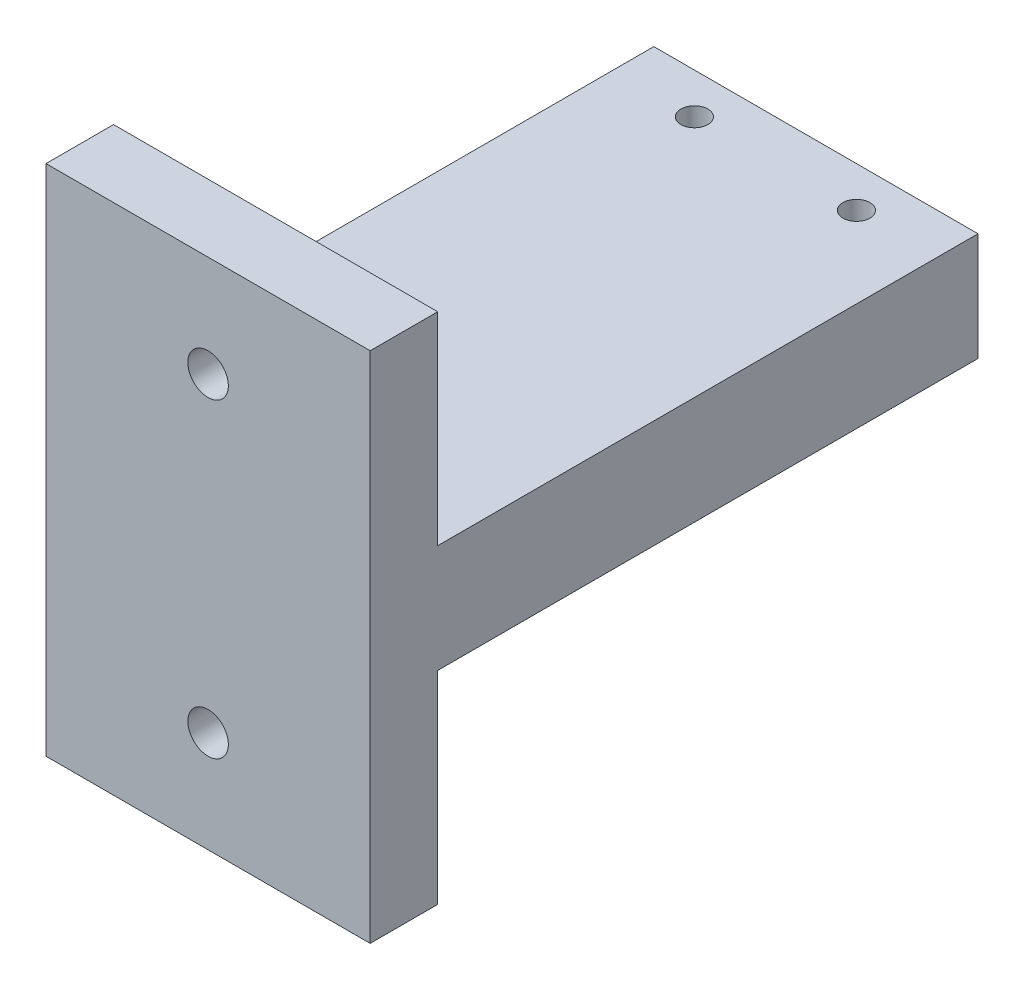
from build123d import *

# Parameters (mm, degrees)
SKETCH2_W           = 24
SKETCH2_H           = 45
BOSS_EXTRUDE1_DEPTH = 8
SKETCH5_W           = 24
SKETCH5_H           = 5
BOSS_EXTRUDE2_DEPTH = 15
SKETCH6_W           = 24
SKETCH6_H           = 5
BOSS_EXTRUDE3_DEPTH = 15
SKETCH7_R           = 1.5
CUT_EXTRUDE1_DEPTH  = 5
SKETCH8_R           = 1
CUT_EXTRUDE2_DEPTH  = 4


with BuildPart() as part:
    # Sketch2 → Boss-Extrude1 (new body)
    with BuildSketch(Plane(origin=(0, 0, 0), x_dir=(1, 0, 0), z_dir=(0, 1, 0))):
        with Locations((-7.196993829, 1.750308141)):
            Rectangle(SKETCH2_W, SKETCH2_H)
    extrude(amount=BOSS_EXTRUDE1_DEPTH)

    # Sketch5 → Boss-Extrude2 (add)
    with BuildSketch(Plane(origin=(0, 8, 0), x_dir=(1, 0, 0), z_dir=(0, 1, 0))):
        with Locations((-7.196993829, -18.249691859)):
            Rectangle(SKETCH5_W, SKETCH5_H)
    extrude(amount=BOSS_EXTRUDE2_DEPTH)

    # Sketch6 → Boss-Extrude3 (add)
    with BuildSketch(Plane.XZ):
        with Locations((-7.196993829, 18.249691859)):
            Rectangle(SKETCH6_W, SKETCH6_H)
    extrude(amount=BOSS_EXTRUDE3_DEPTH)

    # Sketch7 → Cut-Extrude1 (cut)
    with BuildSketch(Plane(origin=(0, 0, 15.749691859), x_dir=(-1, 0, 0), z_dir=(0, 0, -1))):
        with Locations((7.196993829, 15.5)):
            Circle(SKETCH7_R)
        with Locations((7.196993829, -7.5)):
            Circle(SKETCH7_R)
    extrude(amount=-CUT_EXTRUDE1_DEPTH, mode=Mode.SUBTRACT)

    # Sketch8 → Cut-Extrude2 (cut)
    with BuildSketch(Plane(origin=(0, 8, 0), x_dir=(1, 0, 0), z_dir=(0, 1, 0))):
        with Locations((-13.196993829, 21.250308141)):
            Circle(SKETCH8_R)
        with Locations((-1.196993829, 21.250308141)):
            Circle(SKETCH8_R)
    extrude(amount=-CUT_EXTRUDE2_DEPTH, mode=Mode.SUBTRACT)


solid = part.part
